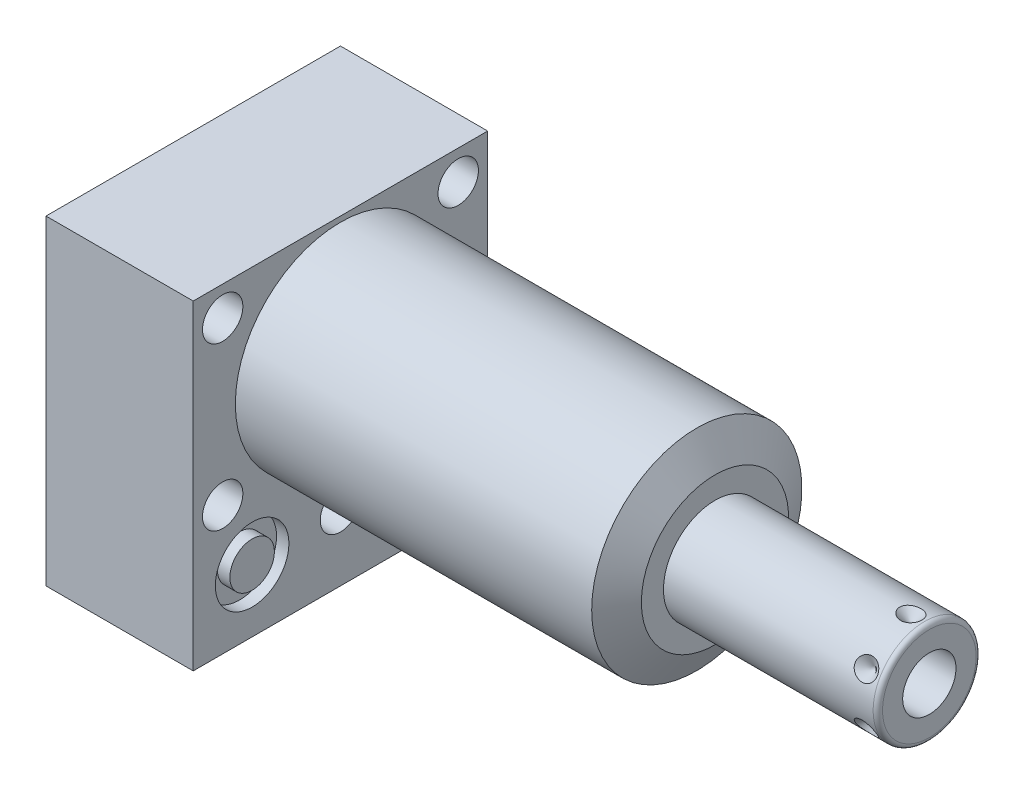
from build123d import *

# Parameters (mm, degrees)
SKETCH1_W           = 63.5
SKETCH1_H           = 69.088
EXTRUDE1_DEPTH      = 80.772
EXTRUDE1_DEPTH_BACK = 31.75
CUT_EXTRUDE1_REACH  = 82.772
SKETCH2_W           = 63.5
SKETCH2_H           = 69.088
SKETCH2_R           = 22.6695
SKETCH18_R          = 7.9375
CUT_EXTRUDE2_DEPTH  = 2.667
SKETCH19_R          = 7.9375
CUT_EXTRUDE3_DEPTH  = 2.667
SKETCH20_R          = 9.525
CUT_EXTRUDE4_DEPTH  = 0.254
SKETCH12_R          = 6.4389
EXTRUDE2_DEPTH      = 1.651
EXTRUDE3_START      = -31.75
SKETCH13_R          = 4.8006
EXTRUDE3_DEPTH      = 31.75
SKETCH14_R          = 1.7653
SKETCH15_R          = 1.7653
CIRPATTERN1_COUNT   = 6
SKETCH21_W          = 4.3561
SKETCH21_H          = 31.75
HOLE1_AT_2_COUNT    = 2
HOLE1_AT_2_PITCH    = 54.58107178
HOLE1_AT_3_COUNT    = 2
HOLE1_AT_3_PITCH    = 34.9504
HOLE1_AT_4_COUNT    = 2
HOLE1_AT_4_PITCH    = 50.8
HOLE1_AT_5_COUNT    = 2
HOLE1_AT_5_PITCH    = 61.661742273


with BuildPart() as part:
    # Sketch1 → Extrude1 (new body, two sides)
    with BuildSketch(Plane(origin=(0, 0, 0), x_dir=(0, 0, -1), z_dir=(1, 0, 0))) as extrude1_sk:
        with Locations((0, -10.7188)):
            Rectangle(SKETCH1_W, SKETCH1_H)
    extrude(amount=EXTRUDE1_DEPTH)
    extrude(extrude1_sk.sketch, amount=-EXTRUDE1_DEPTH_BACK)

    # Sketch2 → Cut-Extrude1 (cut, up to next)
    with BuildSketch(Plane(origin=(0, 0, 0), x_dir=(0, 0, -1), z_dir=(1, 0, 0)), mode=Mode.PRIVATE) as cut_extrude1_sk1:
        with Locations((0, -10.7188)):
            Rectangle(SKETCH2_W, SKETCH2_H)
        Circle(SKETCH2_R, mode=Mode.SUBTRACT)
    cut_extrude1_tool1 = extrude(cut_extrude1_sk1.sketch, amount=CUT_EXTRUDE1_REACH, mode=Mode.PRIVATE) & part.part
    add(cut_extrude1_tool1.solids().sort_by_distance((0, 22.886829, 0))[0], mode=Mode.SUBTRACT)

    # Sketch3 → Cut-Revolve1 (revolve, cut)
    with BuildSketch(Plane.XY, mode=Mode.PRIVATE) as cut_revolve1_sk:
        Polygon((76.849193596, 22.6695), (80.772, 15.875), (80.772, 22.6695), align=None)
    revolve(cut_revolve1_sk.sketch.rotate(Axis((76.037136009, 0, 0), (1, 0, 0)), 90), axis=Axis((76.037136009, 0, 0), (1, 0, 0)), mode=Mode.SUBTRACT)  # turned: the seam where the file's is

    # S2D0002 → Cut-Revolve2 (revolve, cut)
    with BuildSketch(Plane(origin=(-29.083, -31.75, 19.05), x_dir=(0, 1, 0), z_dir=(0, 0, 1)), mode=Mode.PRIVATE) as cut_revolve2_sk:
        Polygon((0, 0), (4.5466, 0), (4.106586662, -2.0701), (3.4544, -2.722286662), (3.4544, -13.97), (0, -13.97), align=None)
    revolve(cut_revolve2_sk.sketch.rotate(Axis((-14.4145, -31.75, 19.05), (-1, 0, 0)), 90), axis=Axis((-14.4145, -31.75, 19.05), (-1, 0, 0)), mode=Mode.SUBTRACT)  # turned: the seam where the file's is

    # Sketch5 → Cut-Revolve3 (revolve, cut)
    with BuildSketch(Plane(origin=(-29.083, -31.75, -19.05), x_dir=(0, 1, 0), z_dir=(0, 0, 1)), mode=Mode.PRIVATE) as cut_revolve3_sk:
        Polygon((0, 0), (4.5466, 0), (4.106586662, -2.0701), (3.4544, -2.722286662), (3.4544, -13.97), (0, -13.97), align=None)
    revolve(cut_revolve3_sk.sketch.rotate(Axis((-14.4145, -31.75, -19.05), (-1, 0, 0)), 90), axis=Axis((-14.4145, -31.75, -19.05), (-1, 0, 0)), mode=Mode.SUBTRACT)  # turned: the seam where the file's is

    # Sketch6 → Cut-Revolve4 (revolve, cut)
    with BuildSketch(Plane(origin=(-2.667, -31.75, 19.05), x_dir=(0, -1, 0), z_dir=(0, 0, 1)), mode=Mode.PRIVATE) as cut_revolve4_sk:
        Polygon((0, 0), (4.5466, 0), (4.106586662, -2.0701), (3.4544, -2.722286662), (3.4544, -12.192), (0, -12.192), align=None)
    revolve(cut_revolve4_sk.sketch.rotate(Axis((-15.4686, -31.75, 19.05), (1, 0, 0)), 90), axis=Axis((-15.4686, -31.75, 19.05), (1, 0, 0)), mode=Mode.SUBTRACT)  # turned: the seam where the file's is

    # Sketch7 → Cut-Revolve5 (revolve, cut)
    with BuildSketch(Plane(origin=(-2.667, -31.75, -19.05), x_dir=(0, -1, 0), z_dir=(0, 0, 1)), mode=Mode.PRIVATE) as cut_revolve5_sk:
        Polygon((0, 0), (4.5466, 0), (4.106586662, -2.0701), (3.4544, -2.722286662), (3.4544, -12.192), (0, -12.192), align=None)
    revolve(cut_revolve5_sk.sketch.rotate(Axis((-15.4686, -31.75, -19.05), (1, 0, 0)), 90), axis=Axis((-15.4686, -31.75, -19.05), (1, 0, 0)), mode=Mode.SUBTRACT)  # turned: the seam where the file's is

    # Sketch8 → Cut-Revolve6 (revolve, cut)
    with BuildSketch(Plane(origin=(-15.875, -51.6128, 19.05), x_dir=(-1, 0, 0), z_dir=(0, 0, 1)), mode=Mode.PRIVATE) as cut_revolve6_sk:
        Polygon((0, -6.604), (6.1849, -6.604), (5.642306865, -9.1567), (4.9784, -9.820606865), (4.9784, -25.654), (0, -25.654), align=None)
    revolve(cut_revolve6_sk.sketch.rotate(Axis((-15.875, -24.9428, 19.05), (0, -1, 0)), 270), axis=Axis((-15.875, -24.9428, 19.05), (0, -1, 0)), mode=Mode.SUBTRACT)  # turned: the seam where the file's is

    # Sketch9 → Cut-Revolve7 (revolve, cut)
    with BuildSketch(Plane(origin=(-15.875, -51.6128, -19.05), x_dir=(-1, 0, 0), z_dir=(0, 0, 1)), mode=Mode.PRIVATE) as cut_revolve7_sk:
        Polygon((0, -6.604), (6.1849, -6.604), (5.642306865, -9.1567), (4.9784, -9.820606865), (4.9784, -25.654), (0, -25.654), align=None)
    revolve(cut_revolve7_sk.sketch.rotate(Axis((-15.875, -24.9428, -19.05), (0, -1, 0)), 270), axis=Axis((-15.875, -24.9428, -19.05), (0, -1, 0)), mode=Mode.SUBTRACT)  # turned: the seam where the file's is

    # Sketch18 → Cut-Extrude2 (cut)
    with BuildSketch(Plane(origin=(0, 0, 0), x_dir=(0, 0, -1), z_dir=(1, 0, 0))):
        with Locations((-19.05, -31.75)):
            Circle(SKETCH18_R)
        with Locations((19.05, -31.75)):
            Circle(SKETCH18_R)
    extrude(amount=-CUT_EXTRUDE2_DEPTH, mode=Mode.SUBTRACT)

    # Sketch19 → Cut-Extrude3 (cut)
    with BuildSketch(Plane.ZY.offset(31.75)):
        with Locations(Location((-19.05, -31.75, 0), (0, 0, 180))):  # turned: the seam where the file's is
            Circle(SKETCH19_R)
        with Locations(Location((19.05, -31.75, 0), (0, 0, 180))):  # turned: the seam where the file's is
            Circle(SKETCH19_R)
    extrude(amount=-CUT_EXTRUDE3_DEPTH, mode=Mode.SUBTRACT)

    # Sketch20 → Cut-Extrude4 (cut)
    with BuildSketch(Plane.XZ.offset(45.2628)):
        with Locations(Location((-15.875, -19.05, 0), (0, 0, 270))):  # turned: the seam where the file's is
            Circle(SKETCH20_R)
        with Locations(Location((-15.875, 19.05, 0), (0, 0, 270))):  # turned: the seam where the file's is
            Circle(SKETCH20_R)
    extrude(amount=-CUT_EXTRUDE4_DEPTH, mode=Mode.SUBTRACT)

    # Sketch10 → Revolve1 (revolve)
    with BuildSketch(Plane.XY, mode=Mode.PRIVATE) as revolve1_sk:
        with BuildLine():
            Line((80.772, 0), (80.772, 11.1125))
            Line((80.772, 11.1125), (125.984, 11.1125))
            ThreePointArc((125.984, 11.1125), (126.70242049, 10.81492049), (127, 10.0965))
            Line((127, 10.0965), (127, 0))
            Line((127, 0), (80.772, 0))
        make_face()
    revolve(revolve1_sk.sketch.rotate(Axis((58.270820274, 0, 0), (1, 0, 0)), 90), axis=Axis((58.270820274, 0, 0), (1, 0, 0)))  # turned: the seam where the file's is

    # S2D0001 → Cut-Revolve8 (revolve, cut)
    with BuildSketch(Plane(origin=(118.6434, -5.7531, 0), x_dir=(0, -1, 0), z_dir=(0, 0, 1)), mode=Mode.PRIVATE) as cut_revolve8_sk:
        Polygon((0, 8.3566), (0, -8.6614), (-5.7531, -12.118211227), (-5.7531, 8.3566), align=None)
    revolve(cut_revolve8_sk.sketch.rotate(Axis((84.296273767, 0, 0), (1, 0, 0)), 270), axis=Axis((84.296273767, 0, 0), (1, 0, 0)), mode=Mode.SUBTRACT)  # turned: the seam where the file's is

    # Sketch12 → Extrude2 (add)
    with BuildSketch(Plane(origin=(-31.75, -45.0088, 0), x_dir=(0, 0, -1), z_dir=(0, -1, 0))):
        with Locations((-19.05, 15.875)):
            Circle(SKETCH12_R)
    extrude(amount=EXTRUDE2_DEPTH)

    # Sketch13 → Extrude3 (add)
    with BuildSketch(Plane(origin=(0, 0, 0), x_dir=(0, 0, -1), z_dir=(1, 0, 0)).offset(EXTRUDE3_START)):
        with Locations((-19.05, -31.75)):
            Circle(SKETCH13_R)
    extrude(amount=EXTRUDE3_DEPTH)

    # Sketch16 → Cut-Revolve9 (revolve, cut)
    with BuildSketch(Plane(origin=(114.681, -11.1125, 0), x_dir=(-1, 0, 0), z_dir=(0, 0, 1)), mode=Mode.PRIVATE) as cut_revolve9_sk:
        Polygon((-8.3566, 0), (-5.9436, 0), (-8.3566, -2.413), align=None)
    cut_revolve9 = revolve(cut_revolve9_sk.sketch.rotate(Axis((123.0376, -6.093194843, 0), (0, -1, 0)), 90), axis=Axis((123.0376, -6.093194843, 0), (0, -1, 0)), mode=Mode.SUBTRACT)  # turned: the seam where the file's is

    # CirPattern1: Cut-Revolve9 ×6 about axis
    cirpattern1_axis = Axis((0, 0, 0), (-1, 0, 0))
    for i in range(1, CIRPATTERN1_COUNT):
        add(cut_revolve9.rotate(cirpattern1_axis, i * 360 / CIRPATTERN1_COUNT), mode=Mode.SUBTRACT)

    # Sketch21 → Hole1 (revolve, cut)
    with BuildSketch(Plane(origin=(0, 17.4752, 25.4), x_dir=(0, 0, -1), z_dir=(0, 1, 0))):
        with Locations((2.17805, 15.875)):
            Rectangle(SKETCH21_W, SKETCH21_H)
    hole1 = revolve(axis=Axis((-110, 17.4752, 25.4), (1, 0, 0)), mode=Mode.SUBTRACT)

    # Hole1 at 2: Hole1 ×2
    with Locations(*[Vector(0, -0.885120032, -0.465362793) * (i * HOLE1_AT_2_PITCH) for i in range(1, HOLE1_AT_2_COUNT)]):
        add(hole1, mode=Mode.SUBTRACT)

    # Hole1 at 3: Hole1 ×2
    with Locations(*[(0, -i * HOLE1_AT_3_PITCH, 0) for i in range(1, HOLE1_AT_3_COUNT)]):
        add(hole1, mode=Mode.SUBTRACT)

    # Hole1 at 4: Hole1 ×2
    with Locations(*[(0, 0, -i * HOLE1_AT_4_PITCH) for i in range(1, HOLE1_AT_4_COUNT)]):
        add(hole1, mode=Mode.SUBTRACT)

    # Hole1 at 5: Hole1 ×2
    with Locations(*[Vector(0, -0.566808506, -0.823849572) * (i * HOLE1_AT_5_PITCH) for i in range(1, HOLE1_AT_5_COUNT)]):
        add(hole1, mode=Mode.SUBTRACT)


with BuildPart() as body_2:
    # Sketch14 → Revolve2 (revolve)
    with BuildSketch(Plane(origin=(0, -31.75, -19.05), x_dir=(0, 0, -1), z_dir=(0, -1, 0)), mode=Mode.PRIVATE) as revolve2_sk:
        with Locations((6.1722, -0.9017)):
            Circle(SKETCH14_R)
    revolve(revolve2_sk.sketch.rotate(Axis((-2.84353, -31.75, -19.05), (1, 0, 0)), 180), axis=Axis((-2.84353, -31.75, -19.05), (1, 0, 0)))  # turned: the seam where the file's is


with BuildPart() as body_3:
    # Sketch15 → Revolve3 (revolve)
    with BuildSketch(Plane(origin=(0, -31.75, -19.05), x_dir=(0, 0, -1), z_dir=(0, -1, 0)), mode=Mode.PRIVATE) as revolve3_sk:
        with Locations((6.1722, -30.8483)):
            Circle(SKETCH15_R)
    revolve(revolve3_sk.sketch.rotate(Axis((-32.79013, -31.75, -19.05), (1, 0, 0)), 180), axis=Axis((-32.79013, -31.75, -19.05), (1, 0, 0)))  # turned: the seam where the file's is


solid = Compound([part.part, body_2.part, body_3.part])
